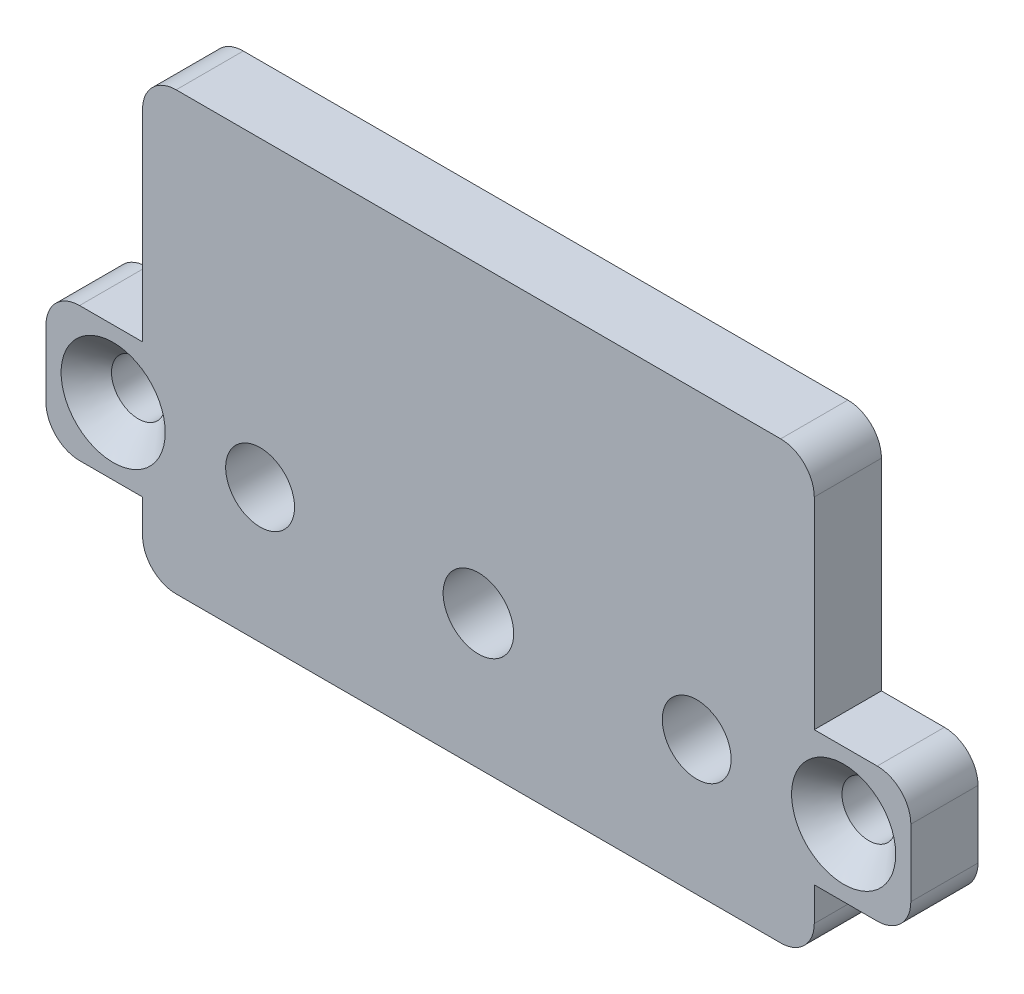
from build123d import *

# Parameters (mm, degrees)
SKETCH_1_R      = 2.05
SKETCH_1_R_2    = 1.6
EXTRUDE_1_DEPTH = 4
FILLET_1_R      = 2
CHAMFER_1_SIZE  = 1.5
FILLET_2_R      = 2


with BuildPart() as part:
    # Эскиз1 → Бобышка-Вытянуть1 (new body)
    with BuildSketch(Plane.XY):
        Polygon((0, 8), (0, 0), (5.75, 0), (5.75, -4), (45.75, -4), (45.75, 0), (51.5, 0), (51.5, 8), (45.75, 8), (45.75, 22), (5.75, 22), (5.75, 8), align=None)
        with Locations((12.75, 4)):
            Circle(SKETCH_1_R, mode=Mode.SUBTRACT)
        with Locations((4, 4)):
            Circle(SKETCH_1_R_2, mode=Mode.SUBTRACT)
        with BuildLine():
            ThreePointArc((27.85, 4), (25.75, 1.9), (23.65, 4))
            ThreePointArc((23.65, 4), (25.75, 6.1), (27.85, 4))
        make_face(mode=Mode.SUBTRACT)
        with Locations((38.75, 4)):
            Circle(SKETCH_1_R, mode=Mode.SUBTRACT)
        with Locations((47.5, 4)):
            Circle(SKETCH_1_R_2, mode=Mode.SUBTRACT)
    extrude(amount=EXTRUDE_1_DEPTH)

    # Скругление1
    fillet_1_edges = [part.edges().sort_by_distance(p)[0] for p in [
        (0, 0, 2),
        (0, 8, 2),
        (51.5, 8, 2),
        (51.5, 0, 2),
    ]]
    fillet(fillet_1_edges, radius=FILLET_1_R)

    # Фаска1
    chamfer_1_edges = [part.edges().sort_by_distance(p)[0] for p in [
        (2.4, 4, 4),
        (45.9, 4, 4),
    ]]
    chamfer(chamfer_1_edges, length=CHAMFER_1_SIZE)

    # Скругление2
    fillet_2_edges = [part.edges().sort_by_distance(p)[0] for p in [
        (5.75, 22, 2),
        (45.75, 22, 2),
        (45.75, -4, 2),
        (5.75, -4, 2),
    ]]
    fillet(fillet_2_edges, radius=FILLET_2_R)


solid = part.part
